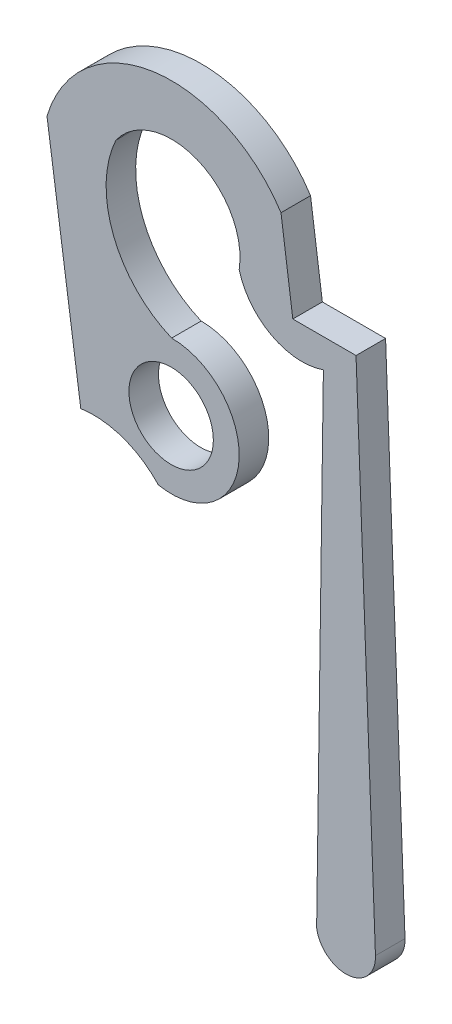
from build123d import *

# Parameters (mm, degrees)
SKETCH1_R           = 1.27
BOSS_EXTRUDE1_DEPTH = 0.889


with BuildPart() as part:
    # Sketch1 → Boss-Extrude1 (new body)
    with BuildSketch(Plane.XY):
        with BuildLine():
            Line((-4.547993368, 7.962766742), (-3.531993368, 0.850766742))
            ThreePointArc((-3.531993368, 0.850766742), (-2.264773091, 0.726570958), (-1.1995543, 0.029017555))
            ThreePointArc((-1.1995543, 0.029017555), (1.223134016, 1.819786094), (-0.798867095, 4.053120405))
            ThreePointArc((-0.798867095, 4.053120405), (-2.550299683, 5.854814329), (-2.477808037, 8.36645962))
            ThreePointArc((-2.477808037, 8.36645962), (-0.021575309, 9.082238313), (1.232714018, 6.852400507))
            ThreePointArc((1.232714018, 6.852400507), (2.205993955, 5.627515221), (3.765914813, 5.508080224))
            Line((3.765914813, 5.508080224), (3.562714813, -9.122319776))
            ThreePointArc((3.562714813, -9.122319776), (4.52052525, -9.888145198), (5.331956505, -8.968651464))
            Line((5.331956505, -8.968651464), (4.747756505, 6.372948536))
            Line((4.747756505, 6.372948536), (2.846185733, 6.372948536))
            Line((2.846185733, 6.372948536), (2.490585733, 8.963748536))
            ThreePointArc((2.490585733, 8.963748536), (-1.349608466, 10.719754973), (-4.547993368, 7.962766742))
        make_face()
        with Locations((-0.814199649, 2.021120405)):
            Circle(SKETCH1_R, mode=Mode.SUBTRACT)
    extrude(amount=BOSS_EXTRUDE1_DEPTH)


solid = part.part
